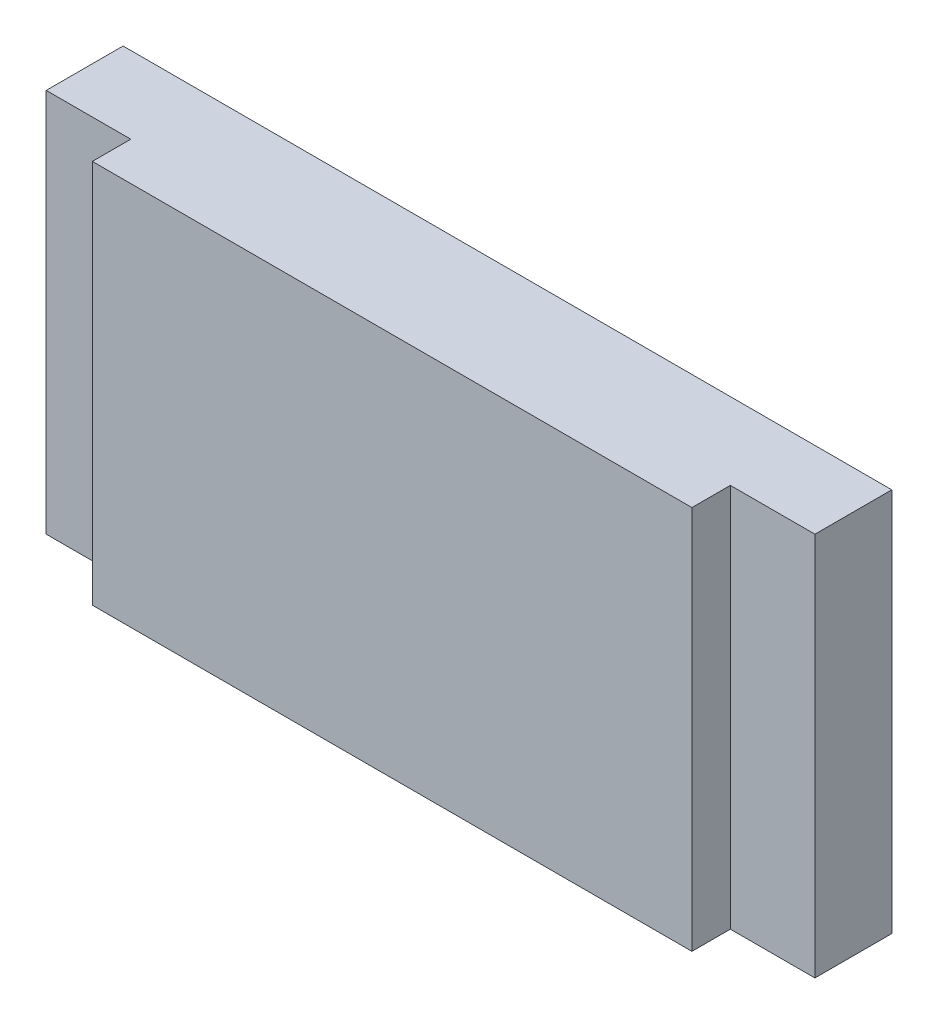
from build123d import *

# Parameters (mm, degrees)
BOSS_EXTRUDE1_DEPTH = 50


with BuildPart() as part:
    # Sketch1 → Boss-Extrude1 (new body)
    with BuildSketch(Plane(origin=(0, 0, 0), x_dir=(1, 0, 0), z_dir=(0, 1, 0))):
        Polygon((-66.087108014, 10.50174216), (33.912891986, 10.50174216), (33.912891986, 0.50174216), (22.912891986, 0.50174216), (22.912891986, -4.49825784), (-55.087108014, -4.49825784), (-55.087108014, 0.50174216), (-66.087108014, 0.50174216), align=None)
    extrude(amount=BOSS_EXTRUDE1_DEPTH)


solid = part.part
